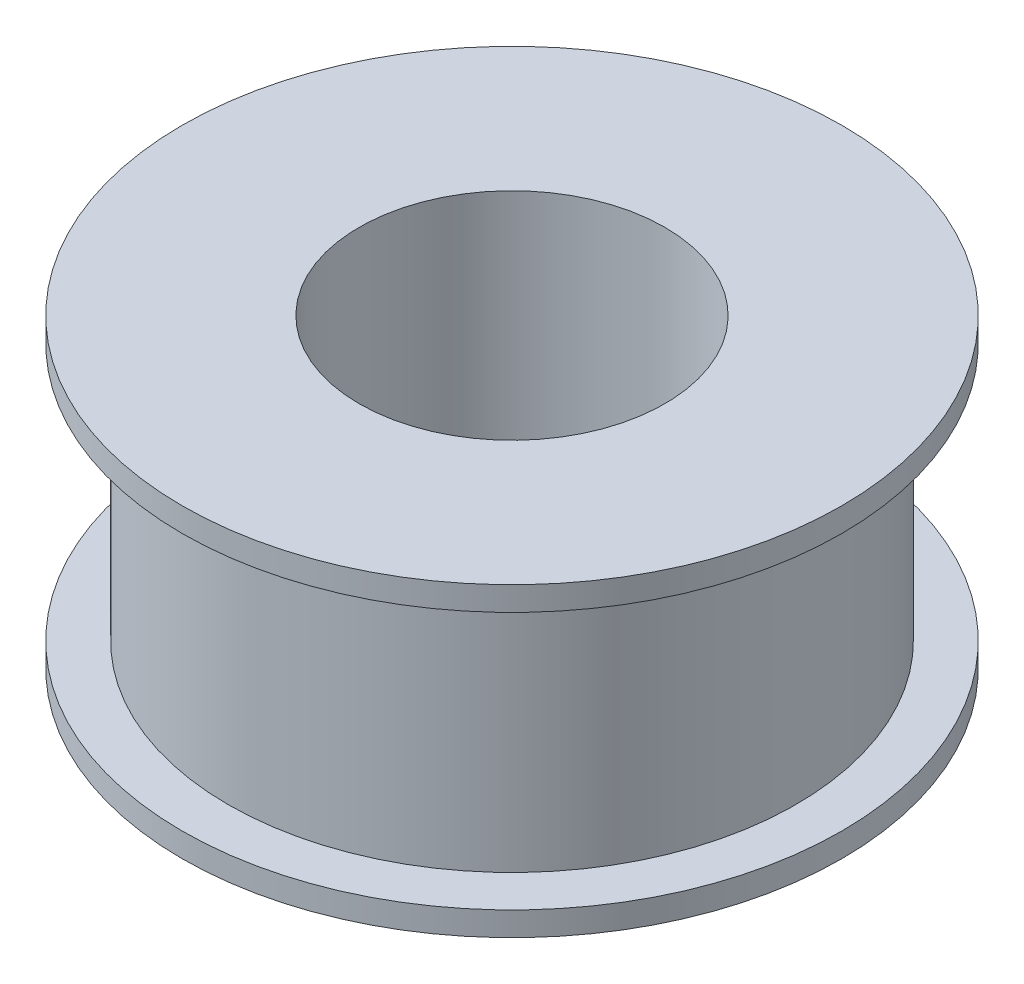
from build123d import *


with BuildPart() as part:
    # Sketch1 → Revolve1 (revolve)
    with BuildSketch(Plane(origin=(0, 0, 0), x_dir=(0, 0, -1), z_dir=(1, 0, 0))):
        Polygon((-7, -7), (-7, 7), (-15.1, 7), (-15.1, 5.9), (-13, 5.9), (-13, -5.9), (-15.1, -5.9), (-15.1, -7), align=None)
    revolve(axis=Axis((0, 7.7, 0), (0, -1, 0)))


solid = part.part
